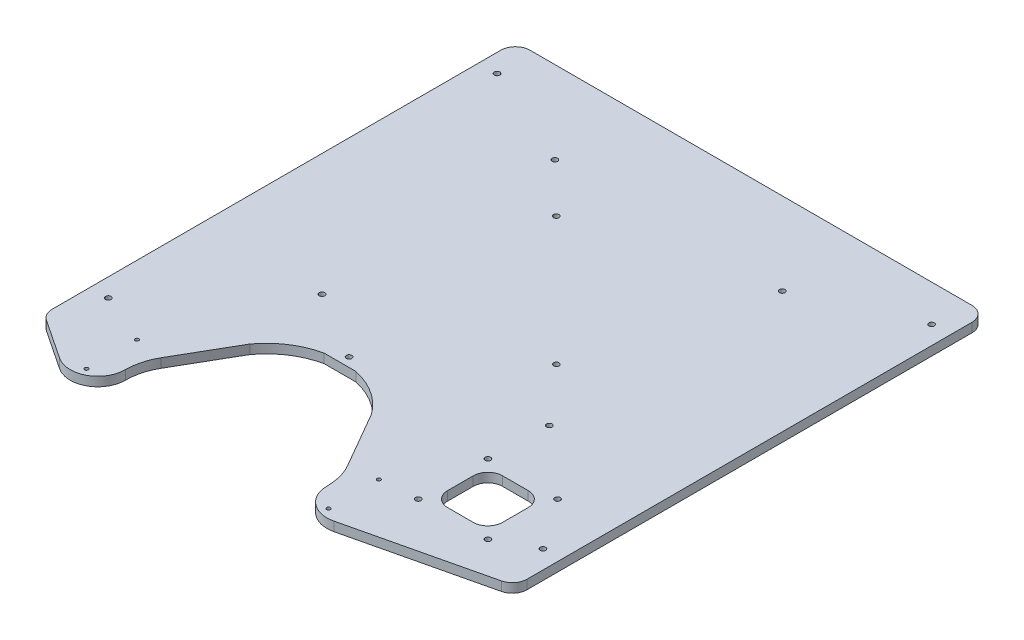
from build123d import *

# Parameters (mm, degrees)
ESQUISSE1_R             = 1
BOSS_EXTRU_1_DEPTH      = 5
ESQUISSE2_R             = 1.5
ENL_V_MAT_EXTRU_1_DEPTH = 6
ESQUISSE3_R             = 1.5
ENL_V_MAT_EXTRU_2_DEPTH = 6
ESQUISSE4_R             = 1.5
ENL_V_MAT_EXTRU_3_DEPTH = 6
ESQUISSE5_R             = 1.5
ENL_V_MAT_EXTRU_5_DEPTH = 6


with BuildPart() as part:
    # Esquisse1 → Boss.-Extru.1 (new body)
    with BuildSketch(Plane(origin=(0, 0, 0), x_dir=(1, 0, 0), z_dir=(0, 1, 0))):
        with BuildLine():
            Line((-120.5, 31.2), (120.5, 31.2))
            ThreePointArc((120.5, 31.2), (126.156854249, 28.856854249), (128.5, 23.2))
            Line((128.5, 23.2), (128.5, -219.467382599))
            ThreePointArc((128.5, -219.467382599), (126.772639772, -224.43266107), (122.336502426, -227.253733403))
            Line((122.336502426, -227.253733403), (48.443442049, -244.68228088))
            ThreePointArc((48.443442049, -244.68228088), (45.399263454, -245.077558471), (42.33836323, -244.8448408))
            ThreePointArc((42.33836323, -244.8448408), (33.490774319, -239.702526143), (30, -230.082873123))
            ThreePointArc((30, -230.082873123), (28.945508514, -222.073215083), (25.853895909, -214.609402001))
            Line((25.853895909, -214.609402001), (10.681549424, -188.330127019))
            Line((10.681549424, -188.330127019), (8.181549424, -184))
            ThreePointArc((8.181549424, -184), (-2.618897308, -173.730489766), (-16.376585234, -168))
            Line((-16.376585234, -168), (-33.623414766, -168))
            ThreePointArc((-33.623414766, -168), (-47.381102692, -173.730489766), (-58.181549424, -184))
            Line((-58.181549424, -184), (-60.681549424, -188.330127019))
            Line((-60.681549424, -188.330127019), (-75.853895909, -214.609402001))
            ThreePointArc((-75.853895909, -214.609402001), (-78.945508514, -222.073215083), (-80, -230.082873123))
            ThreePointArc((-80, -230.082873123), (-81.87001368, -237.335697347), (-87.013794564, -242.780137503))
            ThreePointArc((-87.013794564, -242.780137503), (-95.194460163, -245.081612578), (-103.312708305, -242.568820449))
            Line((-103.312708305, -242.568820449), (-124.933444429, -228.174488322))
            ThreePointArc((-124.933444429, -228.174488322), (-127.552217929, -225.292381715), (-128.5, -221.515316414))
            Line((-128.5, -221.515316414), (-128.5, 23.2))
            ThreePointArc((-128.5, 23.2), (-126.156854249, 28.856854249), (-120.5, 31.2))
        make_face()
        with Locations((41, -212.75)):
            Circle(ESQUISSE1_R, mode=Mode.SUBTRACT)
        with Locations((41, -240.25)):
            Circle(ESQUISSE1_R, mode=Mode.SUBTRACT)
        with Locations((-91, -212.75)):
            Circle(ESQUISSE1_R, mode=Mode.SUBTRACT)
        with Locations((-91, -240.25)):
            Circle(ESQUISSE1_R, mode=Mode.SUBTRACT)
    extrude(amount=-BOSS_EXTRU_1_DEPTH)

    # Esquisse2 → Enlèv. mat.-Extru.1 (cut, through all)
    with BuildSketch(Plane(origin=(0, 0, 0), x_dir=(1, 0, 0), z_dir=(0, 1, 0))):
        with Locations((-118.5, 11.2)):
            Circle(ESQUISSE2_R)
        with Locations((-25, -163)):
            Circle(ESQUISSE2_R)
        with Locations((118.5, 11.2)):
            Circle(ESQUISSE2_R)
        with Locations((118.5, -200.8)):
            Circle(ESQUISSE2_R)
        with Locations((-118.5, -200.8)):
            Circle(ESQUISSE2_R)
    extrude(amount=-ENL_V_MAT_EXTRU_1_DEPTH, mode=Mode.SUBTRACT)

    # Esquisse3 → Enlèv. mat.-Extru.2 (cut, through all)
    with BuildSketch(Plane(origin=(0, 0, 0), x_dir=(1, 0, 0), z_dir=(0, 1, 0))):
        with Locations((62, -140.8)):
            Circle(ESQUISSE3_R)
        with Locations((-62, -140.8)):
            Circle(ESQUISSE3_R)
        with Locations((62, -13.8)):
            Circle(ESQUISSE3_R)
        with Locations((-62, -13.8)):
            Circle(ESQUISSE3_R)
    extrude(amount=-ENL_V_MAT_EXTRU_2_DEPTH, mode=Mode.SUBTRACT)

    # Esquisse4 → Enlèv. mat.-Extru.3 (cut, through all)
    with BuildSketch(Plane(origin=(0, 0, 0), x_dir=(1, 0, 0), z_dir=(0, 1, 0))):
        with Locations((-35, -40)):
            Circle(ESQUISSE4_R)
        with Locations((35, -110)):
            Circle(ESQUISSE4_R)
    extrude(amount=-ENL_V_MAT_EXTRU_3_DEPTH, mode=Mode.SUBTRACT)

    # Esquisse5 → Enlèv. mat.-Extru.5 (cut, through all)
    with BuildSketch(Plane(origin=(0, 0, 0), x_dir=(1, 0, 0), z_dir=(0, 1, 0))):
        with Locations((61, -211.3)):
            Circle(ESQUISSE5_R)
        with Locations((99, -211.3)):
            Circle(ESQUISSE5_R)
        with Locations((99, -173.3)):
            Circle(ESQUISSE5_R)
        with Locations((61, -173.3)):
            Circle(ESQUISSE5_R)
        with BuildLine():
            Line((73, -177.3), (87, -177.3))
            ThreePointArc((87, -177.3), (92.656854249, -179.643145751), (95, -185.3))
            Line((95, -185.3), (95, -199.3))
            ThreePointArc((95, -199.3), (92.656854249, -204.956854249), (87, -207.3))
            Line((87, -207.3), (73, -207.3))
            ThreePointArc((73, -207.3), (67.343145751, -204.956854249), (65, -199.3))
            Line((65, -199.3), (65, -185.3))
            ThreePointArc((65, -185.3), (67.343145751, -179.643145751), (73, -177.3))
        make_face()
    extrude(amount=-ENL_V_MAT_EXTRU_5_DEPTH, mode=Mode.SUBTRACT)


solid = part.part
